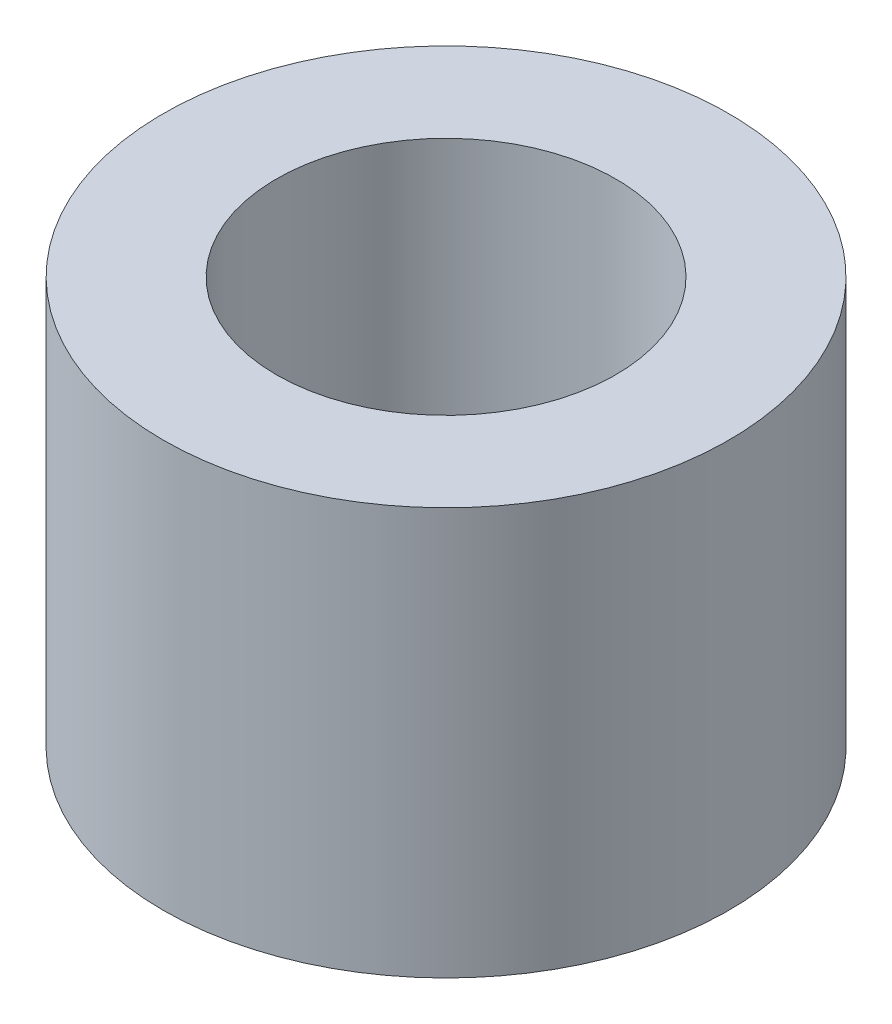
from build123d import *

# Parameters (mm, degrees)
ESQUISSE1_R      = 1.25
ESQUISSE1_R_2    = 0.75
EXTRUSION1_DEPTH = 1.8


with BuildPart() as part:
    # Esquisse1 → Extrusion1 (new body)
    with BuildSketch(Plane(origin=(0, 0, 0), x_dir=(1, 0, 0), z_dir=(0, 1, 0))):
        with Locations(Location((0, 0, 0), (0, 0, 270))):  # turned: the seam where the file's is
            Circle(ESQUISSE1_R)
        with Locations(Location((0, 0, 0), (0, 0, 270))):  # turned: the seam where the file's is
            Circle(ESQUISSE1_R_2, mode=Mode.SUBTRACT)
    extrude(amount=EXTRUSION1_DEPTH)


solid = part.part
